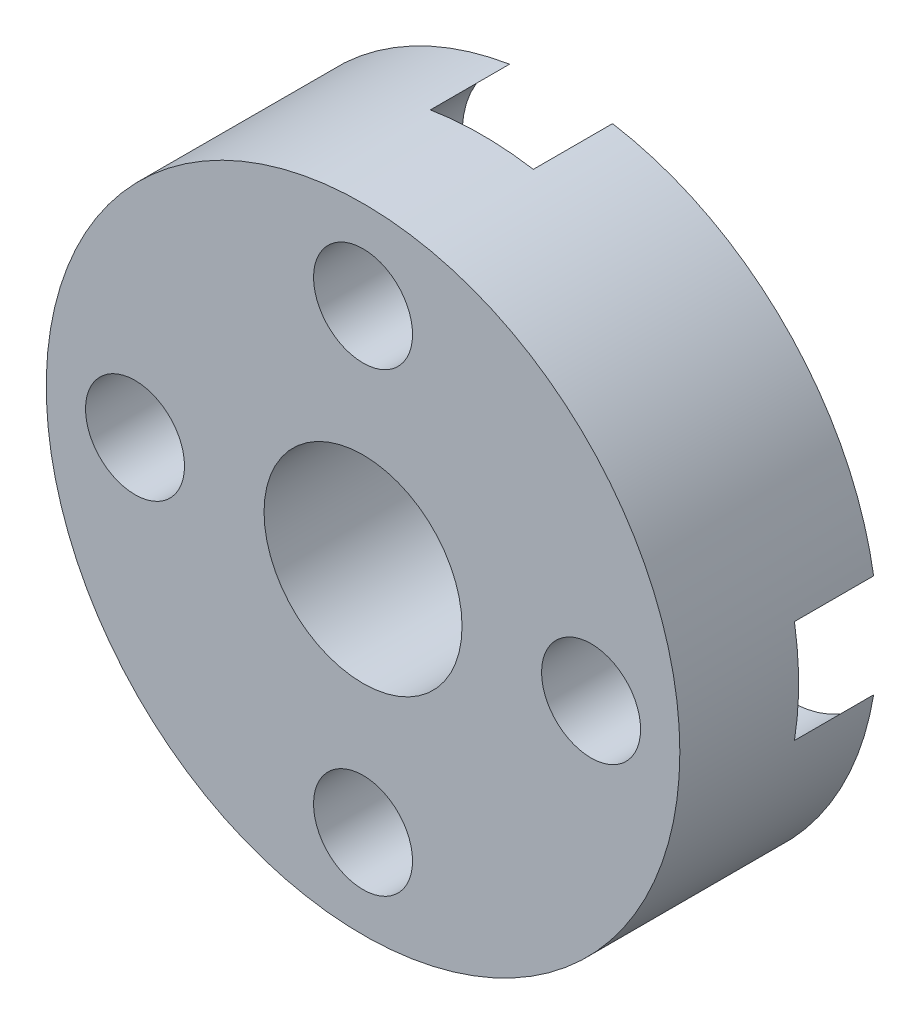
from build123d import *

# Parameters (mm, degrees)
SKETCH_1_R          = 8
SKETCH_1_R_2        = 2.5
SKETCH_1_R_3        = 1.25
EXTRUDE_1_DEPTH     = 5
SKETCH_2_R          = 2.5
CUT_EXTRUDE_1_DEPTH = 2


with BuildPart() as part:
    # 草图1 → 凸台-拉伸1 (new body)
    with BuildSketch(Plane.XY):
        with Locations((-420.454135706, 61.666363326)):
            Circle(SKETCH_1_R)
        with Locations((-420.454135706, 61.666363326)):
            Circle(SKETCH_1_R_2, mode=Mode.SUBTRACT)
        with Locations((-420.454135706, 67.424629947)):
            Circle(SKETCH_1_R_3, mode=Mode.SUBTRACT)
        with Locations((-414.695869085, 61.666363326)):
            Circle(SKETCH_1_R_3, mode=Mode.SUBTRACT)
        with Locations((-420.454135706, 55.908096705)):
            Circle(SKETCH_1_R_3, mode=Mode.SUBTRACT)
        with Locations((-426.212402327, 61.666363326)):
            Circle(SKETCH_1_R_3, mode=Mode.SUBTRACT)
    extrude(amount=EXTRUDE_1_DEPTH)

    # 草图2 → 切除-拉伸1 (cut)
    with BuildSketch(Plane(origin=(0, 0, 0), x_dir=(-1, 0, 0), z_dir=(0, 0, -1))):
        with Locations((420.454135706, 67.424629947)):
            Circle(SKETCH_2_R)
        with Locations((426.212402327, 61.666363326)):
            Circle(SKETCH_2_R)
        with Locations((420.454135706, 55.908096705)):
            Circle(SKETCH_2_R)
        with Locations((414.695869085, 61.666363326)):
            Circle(SKETCH_2_R)
    extrude(amount=-CUT_EXTRUDE_1_DEPTH, mode=Mode.SUBTRACT)


solid = part.part
